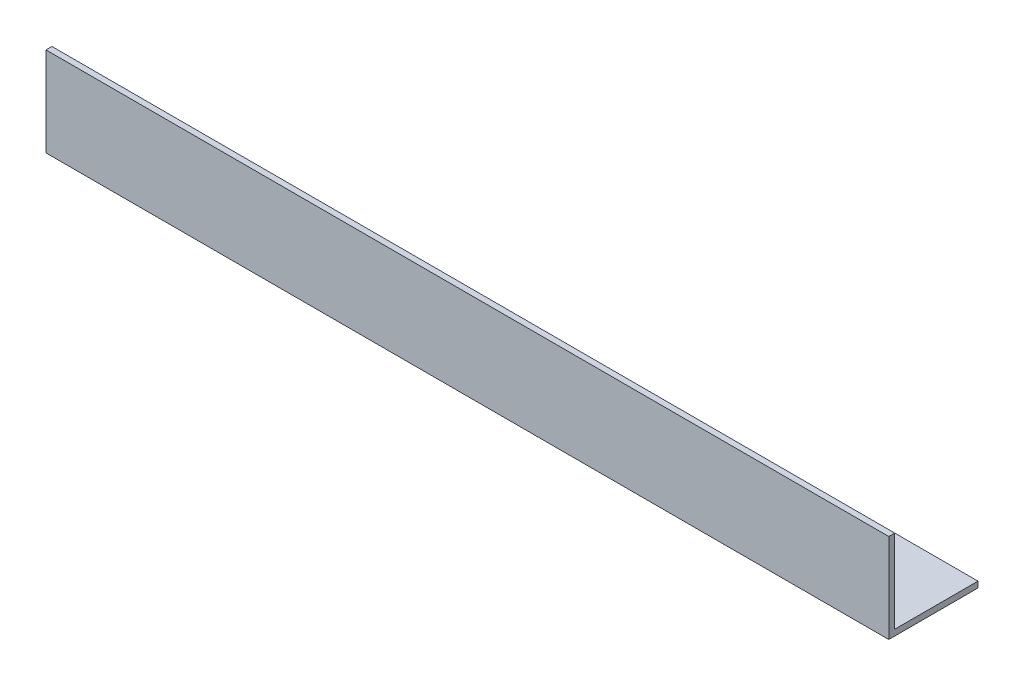
from build123d import *

# Parameters (mm, degrees)
EXTRUDE_1_DEPTH = 425


with BuildPart() as part:
    # Эскиз1 → Вытянуть-Тонкостенный1 (new body)
    with BuildSketch(Plane(origin=(0, 0, 0), x_dir=(0, 0, -1), z_dir=(1, 0, 0))):
        Polygon((45, 0), (0, 0), (0, 45), (3, 45), (3, 3), (45, 3), align=None)
    extrude(amount=EXTRUDE_1_DEPTH)


solid = part.part
